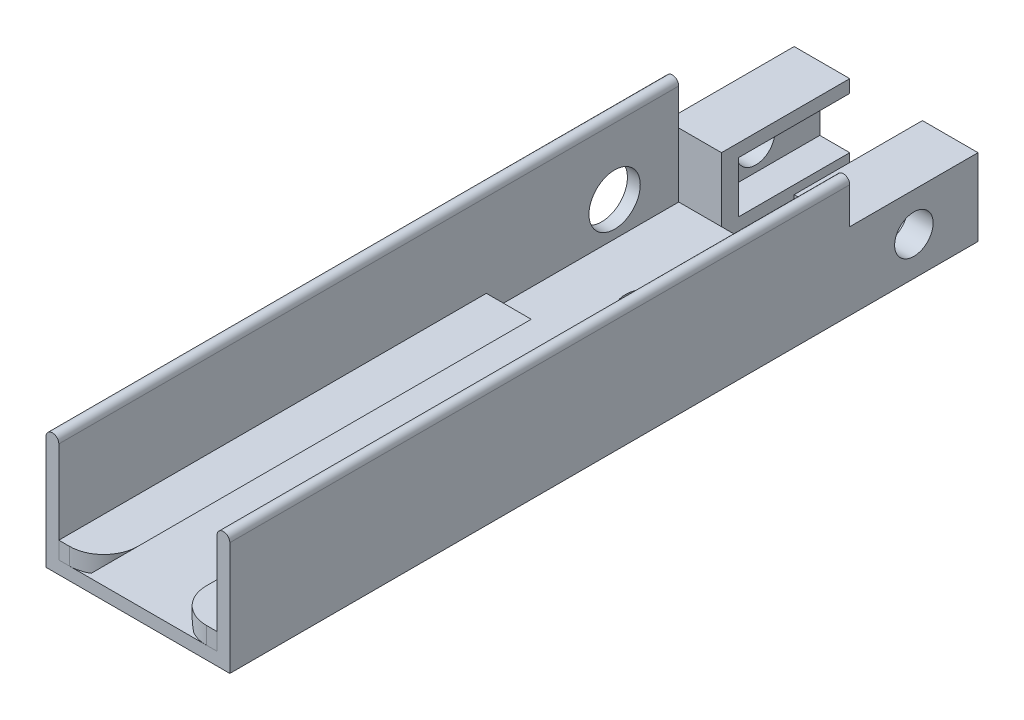
from build123d import *

# Parameters (mm, degrees)
SKETCH1_W                   = 4.3
SKETCH1_H                   = 14.5
NP_HOLDER_BASE_DEPTH        = 2.5
NP_HOLDER_THICKNESS_T       = -0.3
NP2_0_IMEC_DOVETAIL_DEPTH   = 10
NP2_0_IMEC_DOVETAIL_2_DEPTH = 10
SKETCH6_W                   = 0.3
SKETCH6_H                   = 0.15
INNER_PIECE_RAILS_DEPTH     = 14.5
EXTRACTION_HOOKS_DEPTH      = 3
SKETCH8_R                   = 0.45
EXTRACTION_HOLE_DEPTH       = 4.3
SKETCH15_W                  = 0.7
SKETCH15_H                  = 1.2
EXTRACTIONSTOPPER_DEPTH     = 0.4
SKETCH12_R                  = 0.6
ADHESIVE_HOLE_DEPTH         = 0.3
SKETCH13_R                  = 0.6
VERTICAL_ANCHOR_HOLE_DEPTH  = 0.3
ENTRY_EDGE_SMOOTHING_DEPTH  = 0.4


with BuildPart() as part:
    # Sketch1 → NP holder base (new body)
    with BuildSketch(Plane(origin=(0, 0, 0), x_dir=(1, 0, 0), z_dir=(0, 1, 0))):
        Rectangle(SKETCH1_W, SKETCH1_H)
    extrude(amount=NP_HOLDER_BASE_DEPTH)

    # NP holder thickness
    np_holder_thickness_openings = [part.faces().sort_by_distance(p)[0] for p in [
        (0, 2.5, 0),
        (0, 1.25, 7.25),
        (0, 1.25, -7.25),
    ]]
    offset(amount=NP_HOLDER_THICKNESS_T, openings=np_holder_thickness_openings, kind=Kind.INTERSECTION)

    # Sketch6 → inner piece rails (add)
    with BuildSketch(Plane.XY.offset(7.25)):
        with Locations((-2, 2.575)):
            Rectangle(SKETCH6_W, SKETCH6_H)
        with BuildLine():
            ThreePointArc((-2.15, 2.65), (-2, 2.8), (-1.85, 2.65))
            Line((-1.85, 2.65), (-2.15, 2.65))
        make_face()
        with BuildLine():
            ThreePointArc((1.85, 2.65), (2, 2.8), (2.15, 2.65))
            Line((2.15, 2.65), (1.85, 2.65))
        make_face()
        with Locations((2, 2.575)):
            Rectangle(SKETCH6_W, SKETCH6_H)
    extrude(amount=-INNER_PIECE_RAILS_DEPTH)

    # Sketch7 → extraction hooks (add)
    with BuildSketch(Plane(origin=(0, 0, -7.25), x_dir=(-1, 0, 0), z_dir=(0, 0, -1))):
        Polygon((-2.15, 1.8), (-2.15, 0), (-0.85, 0), (-0.85, 0.3), (-1.55, 0.3), (-1.55, 1.5), (-0.85, 1.5), (-0.85, 1.8), align=None)
        Polygon((0.85, 0.3), (0.85, 0), (2.15, 0), (2.15, 1.8), (0.85, 1.8), (0.85, 1.5), (1.55, 1.5), (1.55, 0.3), align=None)
    extrude(amount=EXTRACTION_HOOKS_DEPTH)

    # Sketch8 → extraction hole (cut)
    with BuildSketch(Plane(origin=(2.15, 0, 0), x_dir=(0, 0, -1), z_dir=(1, 0, 0))):
        with Locations((8.75, 0.9)):
            Circle(SKETCH8_R)
    extrude(amount=-EXTRACTION_HOLE_DEPTH, mode=Mode.SUBTRACT)

    # Sketch15 → extractionstopper (add)
    with BuildSketch(Plane.XY.offset(-7.25)):
        with Locations((1.2, 0.9)):
            Rectangle(SKETCH15_W, SKETCH15_H)
        with Locations((-1.2, 0.9)):
            Rectangle(SKETCH15_W, SKETCH15_H)
    extrude(amount=-EXTRACTIONSTOPPER_DEPTH)

    # Sketch12 → adhesive Hole (cut)
    with BuildSketch(Plane.XZ):
        with Locations((0, -4.75)):
            Circle(SKETCH12_R)
    extrude(amount=-ADHESIVE_HOLE_DEPTH, mode=Mode.SUBTRACT)

    # Sketch13 → vertical anchor hole (cut)
    with BuildSketch(Plane.ZY.offset(2.15)):
        with Locations((-5.75, 1.1)):
            Circle(SKETCH13_R)
    extrude(amount=-VERTICAL_ANCHOR_HOLE_DEPTH, mode=Mode.SUBTRACT)


with BuildPart() as body_2:
    # Sketch3 → NP2.0 imec dovetail (new body)
    with BuildSketch(Plane(origin=(0, 0, 7.25), x_dir=(-1, 0, 0), z_dir=(0, 0, -1))):
        Polygon((-1.85, 0.3), (-1.85, 0.7), (-0.8, 0.7), (-1.2, 0.3), align=None)
    extrude(amount=NP2_0_IMEC_DOVETAIL_DEPTH)


with BuildPart() as body_3:
    # Sketch3 → NP2.0 imec dovetail 2 (new body)
    with BuildSketch(Plane(origin=(0, 0, 7.25), x_dir=(-1, 0, 0), z_dir=(0, 0, -1))):
        Polygon((1.2, 0.3), (1.85, 0.3), (1.85, 0.7), (0.8, 0.7), align=None)
    extrude(amount=NP2_0_IMEC_DOVETAIL_2_DEPTH)


with BuildPart() as entry_edge_smoothing_tool:
    # Sketch16 → entry edge smoothing (new body)
    with BuildSketch(Plane(origin=(0, 0.7, 0), x_dir=(1, 0, 0), z_dir=(0, 1, 0))):
        with BuildLine():
            Line((-1.6, -7.25), (-0.8, -7.25))
            Line((-0.8, -7.25), (-0.8, -6.45))
            ThreePointArc((-0.8, -6.45), (-1.034314575, -7.015685425), (-1.6, -7.25))
        make_face()
        with BuildLine():
            Line((0.8, -7.25), (0.8, -6.45))
            ThreePointArc((0.8, -6.45), (1.034314575, -7.015685425), (1.6, -7.25))
            Line((1.6, -7.25), (0.8, -7.25))
        make_face()
    extrude(amount=-ENTRY_EDGE_SMOOTHING_DEPTH)


with BuildPart() as body_2_1:
    add(body_2.part)

    # entry edge smoothing: cut by entry_edge_smoothing_tool
    add(entry_edge_smoothing_tool.part, mode=Mode.SUBTRACT)


with BuildPart() as body_3_1:
    add(body_3.part)

    # entry edge smoothing: cut by entry_edge_smoothing_tool
    add(entry_edge_smoothing_tool.part, mode=Mode.SUBTRACT)


solid = Compound([part.part, body_2_1.part, body_3_1.part])
